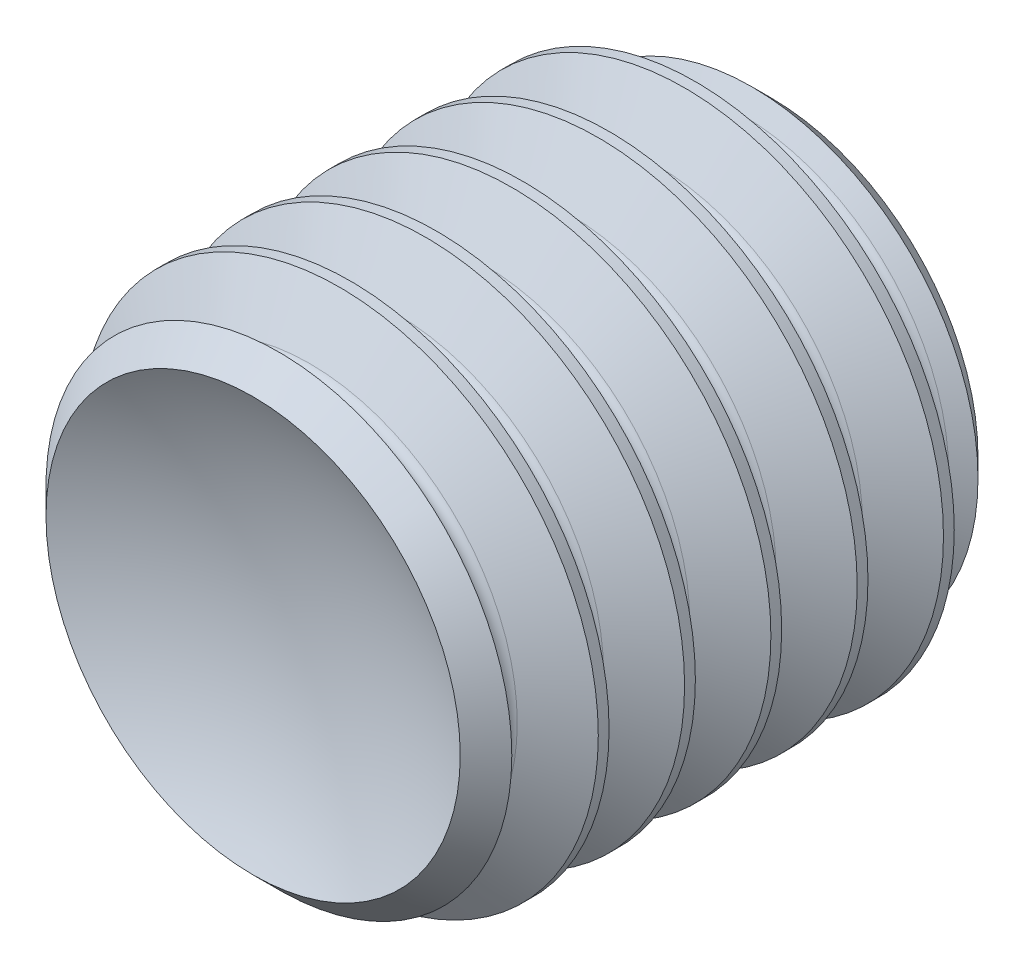
from build123d import *

# Parameters (mm, degrees)
SKETCH5_W           = 3
SKETCH5_H           = 1.5
THREAD_SIMPLE_COUNT = 7
THREAD_SIMPLE_PITCH = 0.5
CUT_HEAD_KEY_DEPTH  = 1.5


with BuildPart() as part:
    # Sketch5 → body (revolve)
    with BuildSketch(Plane(origin=(0, 0, 0), x_dir=(0, 0, -1), z_dir=(1, 0, 0))):
        with Locations((-1.5, 0.75)):
            Rectangle(SKETCH5_W, SKETCH5_H)
    revolve(axis=Axis((0, 0, 3), (0, 0, -1)))

    # Sketch11 → cut-chamfer-start (revolve, cut)
    with BuildSketch(Plane(origin=(0, 0, 0), x_dir=(0, 0, -1), z_dir=(1, 0, 0))):
        Polygon((-3, -1.5), (-3, -1.2), (-2.7, -1.5), align=None)
    revolve(axis=Axis((0, 0, 3), (0, 0, -1)), mode=Mode.SUBTRACT)

    # Sketch13 → cut-chamfer-end (revolve, cut)
    with BuildSketch(Plane(origin=(0, 0, 0), x_dir=(0, 0, -1), z_dir=(1, 0, 0))):
        Polygon((0, -1.5), (-0.3, -1.5), (0, -1.2), align=None)
    revolve(axis=Axis((0, 0, 3), (0, 0, -1)), mode=Mode.SUBTRACT)

    # Sketch8 → thread-single (revolve, cut)
    with BuildSketch(Plane(origin=(0, 0, 0), x_dir=(0, 0, -1), z_dir=(1, 0, 0))):
        with BuildLine():
            Line((-0.4375, -1.5), (0, -1.5))
            Line((0, -1.5), (-0.171875, -1.202303767))
            ThreePointArc((-0.171875, -1.202303767), (-0.21875, -1.175240474), (-0.265625, -1.202303767))
            Line((-0.265625, -1.202303767), (-0.4375, -1.5))
        make_face()
    thread_single = revolve(axis=Axis((0, 0, 3), (0, 0, -1)), mode=Mode.SUBTRACT)

    # thread-simple: thread-single ×7
    with Locations(*[(0, 0, i * THREAD_SIMPLE_PITCH) for i in range(1, THREAD_SIMPLE_COUNT)]):
        add(thread_single, mode=Mode.SUBTRACT)

    # Sketch25 → cut-head-key (cut)
    with BuildSketch(Plane.XY):
        Polygon((0.433012702, 0.75), (-0.433012702, 0.75), (-0.866025404, 0), (-0.433012702, -0.75), (0.433012702, -0.75), (0.866025404, 0), align=None)
    extrude(amount=CUT_HEAD_KEY_DEPTH, mode=Mode.SUBTRACT)

    # Sketch26 → cut-buttom (revolve, cut)
    with BuildSketch(Plane(origin=(0, 0, 0), x_dir=(0, 0, -1), z_dir=(1, 0, 0))):
        with BuildLine():
            Line((-3, 0), (-3, -1.2))
            ThreePointArc((-3, -1.2), (-2.776136625, -0.618465844), (-2.7, 0))
            Line((-2.7, 0), (-3, 0))
        make_face()
    revolve(axis=Axis((0, 0, 3), (0, 0, -1)), mode=Mode.SUBTRACT)


solid = part.part
